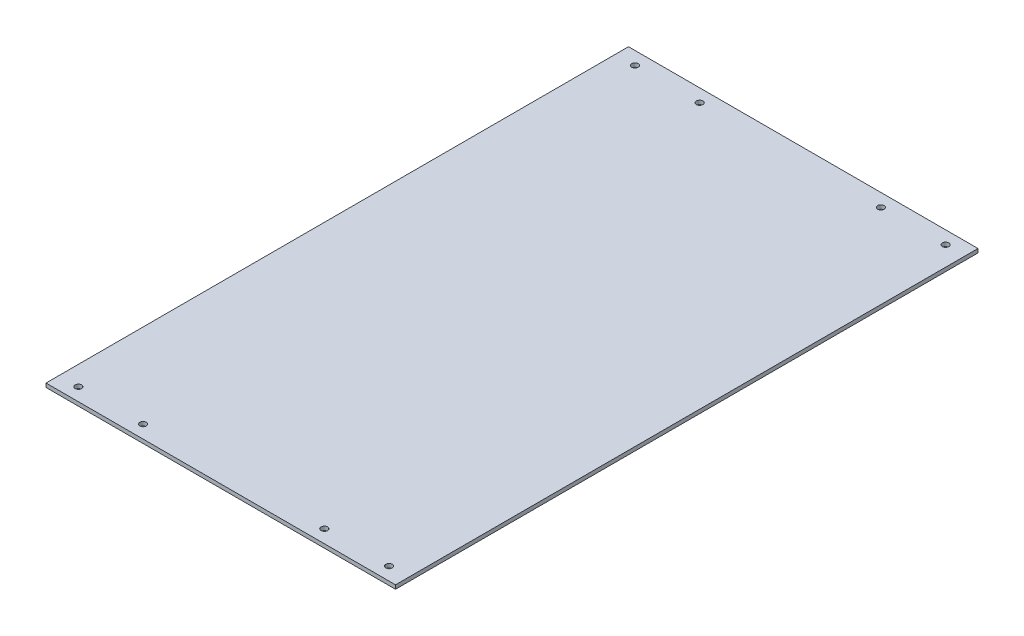
from build123d import *

# Parameters (mm, degrees)
SKETCH1_W           = 270
SKETCH1_H           = 3
BOSS_EXTRUDE1_DEPTH = 450
SKETCH2_R           = 2.5
CUT_EXTRUDE1_DEPTH  = 4


with BuildPart() as part:
    # Sketch1 → Boss-Extrude1 (new body)
    with BuildSketch(Plane.XY):
        Rectangle(SKETCH1_W, SKETCH1_H)
    extrude(amount=-BOSS_EXTRUDE1_DEPTH)

    # Sketch2 → Cut-Extrude1 (cut, through all)
    with BuildSketch(Plane(origin=(0, 1.5, 0), x_dir=(1, 0, 0), z_dir=(0, 1, 0))):
        with Locations((-120, 440)):
            Circle(SKETCH2_R)
        with Locations((-70, 440)):
            Circle(SKETCH2_R)
        with Locations((70, 440)):
            Circle(SKETCH2_R)
        with Locations((120, 440)):
            Circle(SKETCH2_R)
        with Locations((120, 10)):
            Circle(SKETCH2_R)
        with Locations((70, 10)):
            Circle(SKETCH2_R)
        with Locations((-70, 10)):
            Circle(SKETCH2_R)
        with Locations((-120, 10)):
            Circle(SKETCH2_R)
    extrude(amount=-CUT_EXTRUDE1_DEPTH, mode=Mode.SUBTRACT)


solid = part.part
